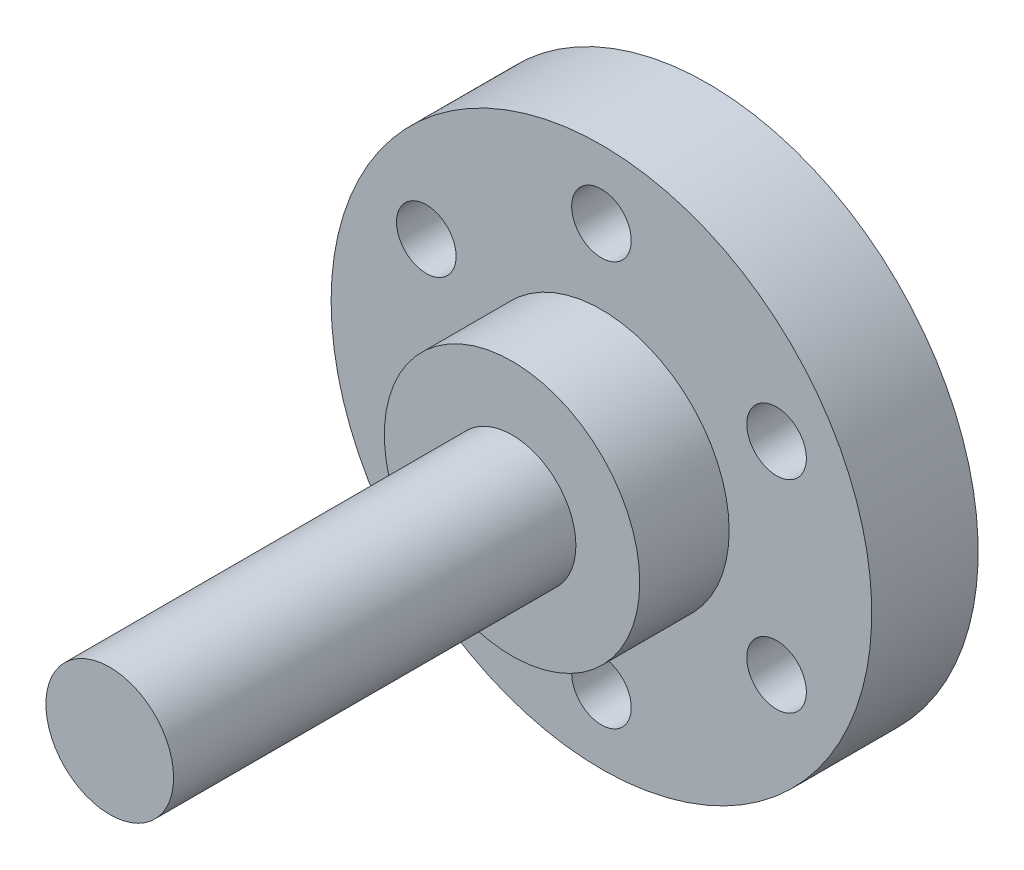
from build123d import *

# Parameters (mm, degrees)
SKETCH1_R           = 3
BOSS_EXTRUDE1_DEPTH = 29
SKETCH2_R           = 6
BOSS_EXTRUDE2_DEPTH = 2.1
SKETCH3_R           = 12.7
BOSS_EXTRUDE3_DEPTH = 5
SKETCH4_R           = 6
BOSS_EXTRUDE4_DEPTH = 2.1
SKETCH10_R          = 1.4
CUT_EXTRUDE1_DEPTH  = 5


with BuildPart() as part:
    # Sketch1 → Boss-Extrude1 (new body)
    with BuildSketch(Plane.XY):
        Circle(SKETCH1_R)
    extrude(amount=BOSS_EXTRUDE1_DEPTH)

    # Sketch2 → Boss-Extrude2 (add)
    with BuildSketch(Plane.XY.offset(8)):
        Circle(SKETCH2_R)
    extrude(amount=-BOSS_EXTRUDE2_DEPTH)

    # Sketch3 → Boss-Extrude3 (add)
    with BuildSketch(Plane(origin=(0, 0, 5.9), x_dir=(-1, 0, 0), z_dir=(0, 0, -1))):
        Circle(SKETCH3_R)
    extrude(amount=BOSS_EXTRUDE3_DEPTH)

    # Sketch4 → Boss-Extrude4 (add)
    with BuildSketch(Plane.XY.offset(8)):
        Circle(SKETCH4_R)
    extrude(amount=BOSS_EXTRUDE4_DEPTH)

    # Sketch10 → Cut-Extrude1 (cut)
    with BuildSketch(Plane(origin=(0, 0, 0.9), x_dir=(-1, 0, 0), z_dir=(0, 0, -1))):
        with Locations((8.227241336, 4.75)):
            Circle(SKETCH10_R)
        with Locations((0, 9.5)):
            Circle(SKETCH10_R)
        with Locations((8.227241336, -4.75)):
            Circle(SKETCH10_R)
        with Locations((0, -9.5)):
            Circle(SKETCH10_R)
        with Locations((-8.227241336, -4.75)):
            Circle(SKETCH10_R)
        with Locations((-8.227241336, 4.75)):
            Circle(SKETCH10_R)
    extrude(amount=-CUT_EXTRUDE1_DEPTH, mode=Mode.SUBTRACT)


solid = part.part
